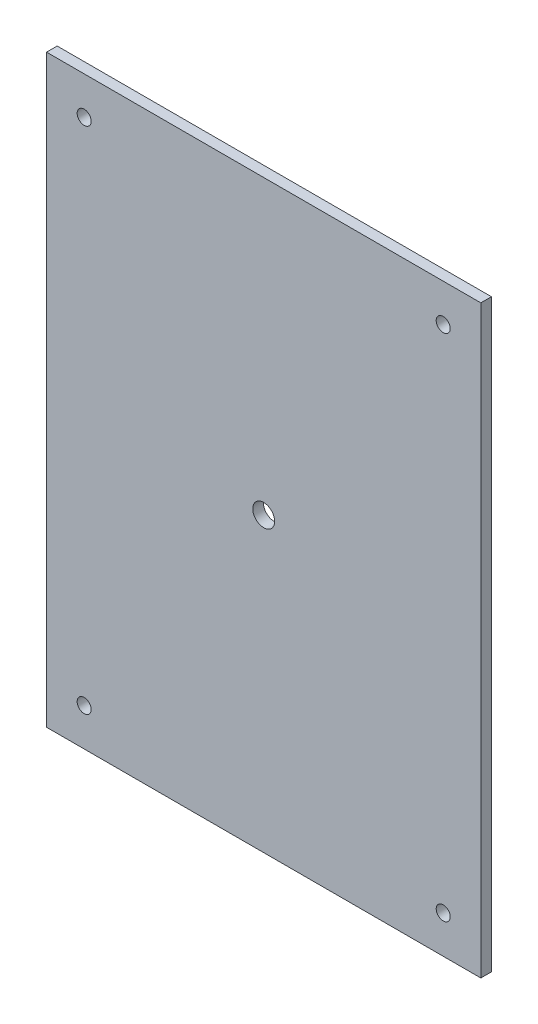
from build123d import *

# Parameters (mm, degrees)
SKETCH1_W                   = 259.8
SKETCH1_H                   = 349.8
BOSS_EXTRUDE1_DEPTH         = 6.35
F_1_2_CLEARANCE_HOLE1_D     = 13.09624
F_1_2_CLEARANCE_HOLE1_DEPTH = 22.352
F_1_2_CLEARANCE_HOLE1_TIP   = 3.934507437
M8_CLEARANCE_HOLE1_D        = 8.4
M8_CLEARANCE_HOLE1_DEPTH    = 76.2
M8_CLEARANCE_HOLE1_TIP      = 2.5236146


with BuildPart() as part:
    # Sketch1 → Boss-Extrude1 (new body)
    with BuildSketch(Plane.XY):
        with Locations((-129.9, 174.9)):
            Rectangle(SKETCH1_W, SKETCH1_H)
    extrude(amount=BOSS_EXTRUDE1_DEPTH)

    # 1/2 Clearance Hole1
    with Locations(Plane.XY.offset(6.35)):
        with Locations((-129.9, 174.9)):
            Hole(F_1_2_CLEARANCE_HOLE1_D / 2, depth=F_1_2_CLEARANCE_HOLE1_DEPTH)
            with Locations((0, 0, -(F_1_2_CLEARANCE_HOLE1_DEPTH + F_1_2_CLEARANCE_HOLE1_TIP / 2))):  # 118° drill point
                Cone(0, F_1_2_CLEARANCE_HOLE1_D / 2, F_1_2_CLEARANCE_HOLE1_TIP, mode=Mode.SUBTRACT)

    # M8 Clearance Hole1
    with Locations(Plane.XY.offset(6.35)):
        with Locations((-237.3, 327.3), (-22.5, 327.3), (-22.5, 22.5), (-237.3, 22.5)):
            Hole(M8_CLEARANCE_HOLE1_D / 2, depth=M8_CLEARANCE_HOLE1_DEPTH)
            with Locations((0, 0, -(M8_CLEARANCE_HOLE1_DEPTH + M8_CLEARANCE_HOLE1_TIP / 2))):  # 118° drill point
                Cone(0, M8_CLEARANCE_HOLE1_D / 2, M8_CLEARANCE_HOLE1_TIP, mode=Mode.SUBTRACT)


solid = part.part
